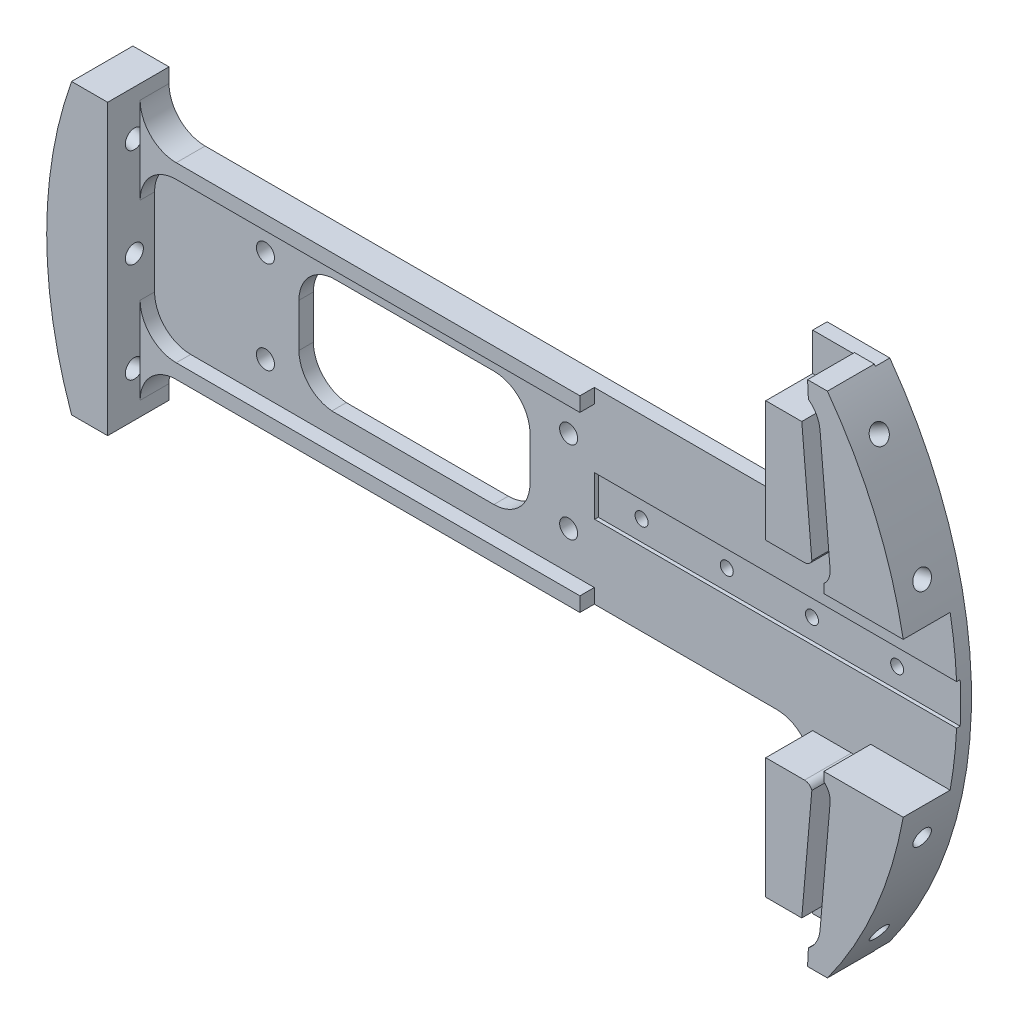
from build123d import *

# Parameters (mm, degrees)
SKETCH1_R           = 1.5875
BOSS_EXTRUDE1_DEPTH = 2.54
BOSS_EXTRUDE2_DEPTH = 8.255
SKETCH3_W           = 64.77
SKETCH3_H           = 7.1
CUT_EXTRUDE1_DEPTH  = 0.635
SKETCH9_R           = 1.5875
CUT_EXTRUDE4_DEPTH  = 3.54
SKETCH4_R           = 1.143
CUT_EXTRUDE2_DEPTH  = 11.43
BOSS_EXTRUDE5_DEPTH = 8.255
SKETCH28_R          = 1.5875
CUT_EXTRUDE12_DEPTH = 7.62
SKETCH29_R          = 1.5875
CUT_EXTRUDE13_DEPTH = 10.16
SKETCH30_R          = 1.5875
CUT_EXTRUDE14_DEPTH = 12.7
SKETCH31_R          = 1.5875
CUT_EXTRUDE15_DEPTH = 12.7
SKETCH32_R          = 1.5875
CUT_EXTRUDE16_DEPTH = 12.7
BOSS_EXTRUDE6_DEPTH = 2.54
CUT_EXTRUDE17_DEPTH = 3.5400001


with BuildPart() as part:
    # Sketch1 → Boss-Extrude1 (new body)
    with BuildSketch(Plane.XY):
        with BuildLine():
            Line((-71.572584947, 25.4), (-65.222584947, 25.4))
            Line((-65.222584947, 25.4), (-65.222584947, 22.86))
            ThreePointArc((-65.222584947, 22.86), (-63.362713008, 18.369871939), (-58.872584947, 16.51))
            Line((-58.872584947, 16.51), (44.196, 16.51))
            ThreePointArc((44.196, 16.51), (48.686128061, 18.369871939), (50.546, 22.86))
            Line((50.546, 22.86), (50.546, 44.45))
            Line((50.546, 44.45), (61.579155694, 44.45))
            ThreePointArc((61.579155694, 44.45), (75.946, 0), (61.579155694, -44.45))
            Line((61.579155694, -44.45), (50.546, -44.45))
            Line((50.546, -44.45), (50.546, -22.86))
            ThreePointArc((50.546, -22.86), (48.686128061, -18.369871939), (44.196, -16.51))
            Line((44.196, -16.51), (-58.872584947, -16.51))
            ThreePointArc((-58.872584947, -16.51), (-63.362713008, -18.369871939), (-65.222584947, -22.86))
            Line((-65.222584947, -22.86), (-65.222584947, -25.4))
            Line((-65.222584947, -25.4), (-71.572584947, -25.4))
            ThreePointArc((-71.572584947, -25.4), (-75.946, 0), (-71.572584947, 25.4))
        make_face()
        with Locations((-45.72, 8.128)):
            Circle(SKETCH1_R, mode=Mode.SUBTRACT)
        with Locations((-45.72, -8.128)):
            Circle(SKETCH1_R, mode=Mode.SUBTRACT)
    extrude(amount=BOSS_EXTRUDE1_DEPTH)

    # Sketch2 → Boss-Extrude2 (add)
    with BuildSketch(Plane.XY.offset(2.54)):
        with BuildLine():
            Line((61.865268471, 17.78), (60.095110466, 38.1))
            ThreePointArc((60.095110466, 38.1), (59.464196764, 40.158289632), (58.047089349, 41.778911391))
            Line((58.047089349, 41.778911391), (57.900800643, 44.704))
            Line((57.900800643, 44.704), (61.395010384, 44.704))
            ThreePointArc((61.395010384, 44.704), (69.822038137, 29.877715884), (74.728381149, 13.544887112))
            Line((74.728381149, 13.544887112), (60.759450402, 13.544887112))
            Line((60.759450402, 13.544887112), (60.759450402, 15.094127876))
            ThreePointArc((60.759450402, 15.094127876), (61.639191639, 16.302501703), (61.865268471, 17.78))
        make_face()
        with BuildLine():
            Line((58.651639318, 17.500047669), (56.881481313, 37.820047669))
            Line((56.881481313, 37.820047669), (50.546, 37.820047669))
            Line((50.546, 37.820047669), (50.546, 16.566735288))
            Line((50.546, 16.566735288), (57.366094516, 16.566735288))
            ThreePointArc((57.366094516, 16.566735288), (58.160401987, 16.824667019), (58.651639318, 17.500047669))
        make_face()
        with BuildLine():
            Line((60.759450402, -13.544887112), (74.728381149, -13.544887112))
            ThreePointArc((74.728381149, -13.544887112), (69.822038137, -29.877715884), (61.395010384, -44.704))
            Line((61.395010384, -44.704), (57.900800643, -44.704))
            Line((57.900800643, -44.704), (58.047089349, -41.778911391))
            ThreePointArc((58.047089349, -41.778911391), (59.464196764, -40.158289632), (60.095110466, -38.1))
            Line((60.095110466, -38.1), (61.865268471, -17.78))
            ThreePointArc((61.865268471, -17.78), (61.639191639, -16.302501703), (60.759450402, -15.094127876))
            Line((60.759450402, -15.094127876), (60.759450402, -13.544887112))
        make_face()
        with BuildLine():
            Line((50.546, -16.566735288), (57.366094516, -16.566735288))
            ThreePointArc((57.366094516, -16.566735288), (58.160401987, -16.824667019), (58.651639318, -17.500047669))
            Line((58.651639318, -17.500047669), (56.881481313, -37.820047669))
            Line((56.881481313, -37.820047669), (50.546, -37.820047669))
            Line((50.546, -37.820047669), (50.546, -16.566735288))
        make_face()
    extrude(amount=BOSS_EXTRUDE2_DEPTH)

    # Sketch3 → Cut-Extrude1 (cut)
    with BuildSketch(Plane.XY.offset(2.54)):
        with Locations((44.577, 0)):
            Rectangle(SKETCH3_W, SKETCH3_H)
    extrude(amount=-CUT_EXTRUDE1_DEPTH, mode=Mode.SUBTRACT)

    # Sketch9 → Cut-Extrude4 (cut, through all)
    with BuildSketch(Plane.XY.offset(2.54)):
        with Locations((7.62, -7.239)):
            Circle(SKETCH9_R)
        with Locations((7.62, 7.239)):
            Circle(SKETCH9_R)
    extrude(amount=-CUT_EXTRUDE4_DEPTH, mode=Mode.SUBTRACT)

    # Sketch4 → Cut-Extrude2 (cut)
    with BuildSketch(Plane.XY.offset(1.905)):
        with Locations((19.812, 0)):
            Circle(SKETCH4_R)
        with Locations((34.798, 0)):
            Circle(SKETCH4_R)
        with Locations((49.784, 0)):
            Circle(SKETCH4_R)
        with Locations((64.77, 0)):
            Circle(SKETCH4_R)
    extrude(amount=-CUT_EXTRUDE2_DEPTH, mode=Mode.SUBTRACT)

    # Sketch19 → Boss-Extrude5 (add)
    with BuildSketch(Plane.XY.offset(2.54)):
        with BuildLine():
            Line((-71.572584947, -25.4), (-65.222584947, -25.4))
            Line((-65.222584947, -25.4), (-65.222584947, 25.4))
            Line((-65.222584947, 25.4), (-71.572584947, 25.4))
            ThreePointArc((-71.572584947, 25.4), (-75.946, 0), (-71.572584947, -25.4))
        make_face()
    extrude(amount=BOSS_EXTRUDE5_DEPTH)

    # Sketch28 → Cut-Extrude12 (cut)
    with BuildSketch(Plane(origin=(65.771165316, 37.973, 0), x_dir=(0, 0, -1), z_dir=(0.866025404, 0.5, 0))):
        with Locations((-6.053310192, 0)):
            Circle(SKETCH28_R)
    cut_extrude12 = extrude(amount=-CUT_EXTRUDE12_DEPTH, mode=Mode.SUBTRACT)

    # Sketch29 → Cut-Extrude13 (cut)
    with BuildSketch(Plane(origin=(73.358202803, 19.656271199, 0), x_dir=(0, 0, -1), z_dir=(0.965925826, 0.258819045, 0))):
        with Locations((-6.096, 0)):
            Circle(SKETCH29_R)
    cut_extrude13 = extrude(amount=-CUT_EXTRUDE13_DEPTH, mode=Mode.SUBTRACT)

    # Mirror3: Cut-Extrude12, Cut-Extrude13 across plane
    add(cut_extrude12.mirror(Plane.ZX), mode=Mode.SUBTRACT)
    add(cut_extrude13.mirror(Plane.ZX), mode=Mode.SUBTRACT)

    # Sketch30 → Cut-Extrude14 (cut)
    with BuildSketch(Plane(origin=(-73.358202803, 19.656271199, 0), x_dir=(0, 0, 1), z_dir=(-0.965925826, 0.258819045, 0))):
        with Locations((6.096, 0)):
            Circle(SKETCH30_R)
    extrude(amount=-CUT_EXTRUDE14_DEPTH, mode=Mode.SUBTRACT)

    # Sketch31 → Cut-Extrude15 (cut)
    with BuildSketch(Plane.ZY.offset(75.946)):
        with Locations((6.096, 0)):
            Circle(SKETCH31_R)
    extrude(amount=-CUT_EXTRUDE15_DEPTH, mode=Mode.SUBTRACT)

    # Sketch32 → Cut-Extrude16 (cut)
    with BuildSketch(Plane(origin=(-73.358202803, -19.656271199, 0), x_dir=(0, 0, 1), z_dir=(-0.965925826, -0.258819045, 0))):
        with Locations((6.096, 0)):
            Circle(SKETCH32_R)
    extrude(amount=-CUT_EXTRUDE16_DEPTH, mode=Mode.SUBTRACT)

    # Sketch33 → Boss-Extrude6 (add)
    with BuildSketch(Plane.XY.offset(2.54)):
        with BuildLine():
            Line((12.137284041, 16.51), (-58.872584947, 16.51))
            ThreePointArc((-58.872584947, 16.51), (-63.362713008, 18.369871939), (-65.222584947, 22.86))
            Line((-65.222584947, 22.86), (-65.222584947, 7.62))
            ThreePointArc((-65.222584947, 7.62), (-63.362713008, 12.110128061), (-58.872584947, 13.97))
            Line((-58.872584947, 13.97), (12.137284041, 13.97))
            Line((12.137284041, 13.97), (12.137284041, 16.51))
        make_face()
        with BuildLine():
            Line((12.137284041, -13.97), (12.137284041, -16.51))
            Line((12.137284041, -16.51), (-58.872584947, -16.51))
            ThreePointArc((-58.872584947, -16.51), (-63.362713008, -18.369871939), (-65.222584947, -22.86))
            Line((-65.222584947, -22.86), (-65.222584947, -7.62))
            ThreePointArc((-65.222584947, -7.62), (-63.362713008, -12.110128061), (-58.872584947, -13.97))
            Line((-58.872584947, -13.97), (12.137284041, -13.97))
        make_face()
    extrude(amount=BOSS_EXTRUDE6_DEPTH)

    # Sketch34 → Cut-Extrude17 (cut, through all)
    with BuildSketch(Plane.XY.offset(2.54)):
        with BuildLine():
            Line((-33.472584947, 10.16), (-5.532584947, 10.16))
            ThreePointArc((-5.532584947, 10.16), (-1.042456886, 8.300128061), (0.817415053, 3.81))
            Line((0.817415053, 3.81), (0.817415053, -3.81))
            ThreePointArc((0.817415053, -3.81), (-1.042456886, -8.300128061), (-5.532584947, -10.16))
            Line((-5.532584947, -10.16), (-34.039131073, -10.16))
            ThreePointArc((-34.039131073, -10.16), (-38.158738375, -8.120468891), (-39.822584947, -3.83532408))
            Line((-39.822584947, -3.83532408), (-39.822584947, 3.81))
            ThreePointArc((-39.822584947, 3.81), (-37.962713008, 8.300128061), (-33.472584947, 10.16))
        make_face()
    extrude(amount=-CUT_EXTRUDE17_DEPTH, mode=Mode.SUBTRACT)


solid = part.part
